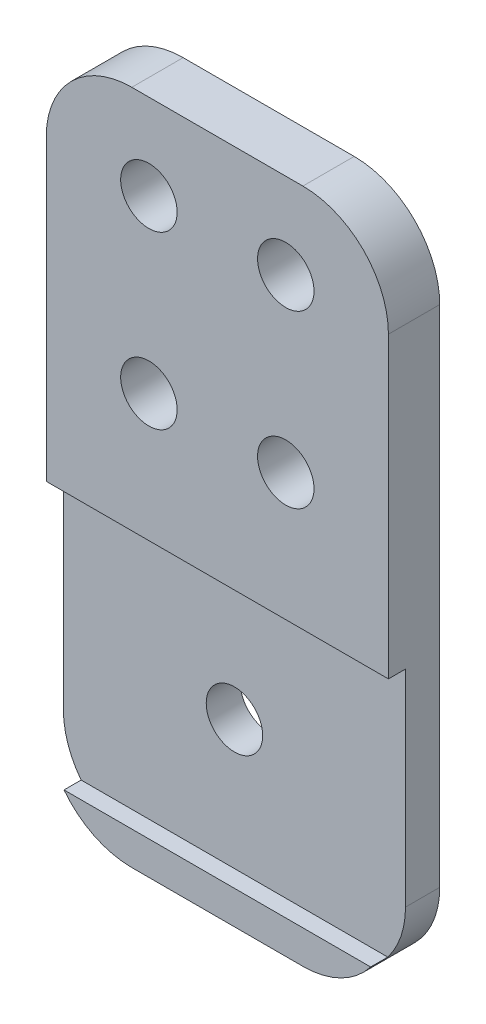
from build123d import *

# Parameters (mm, degrees)
SKETCH_2_W          = 20
SKETCH_2_H          = 39.5
SKETCH_2_R          = 1.65
EXTRUDE_1_DEPTH     = 3
SKETCH_3_W          = 20
SKETCH_3_H          = 15.1
CUT_EXTRUDE_1_DEPTH = 1
FILLET_2_R          = 5


with BuildPart() as part:
    # ｽｹｯﾁ2 → ﾎﾞｽ - 押し出し1 (new body)
    with BuildSketch(Plane.XY):
        with Locations((0, -9.75)):
            Rectangle(SKETCH_2_W, SKETCH_2_H)
        with Locations((-4, 5)):
            Circle(SKETCH_2_R, mode=Mode.SUBTRACT)
        with Locations((-4, -5)):
            Circle(SKETCH_2_R, mode=Mode.SUBTRACT)
        with Locations((4, -5)):
            Circle(SKETCH_2_R, mode=Mode.SUBTRACT)
        with Locations((4, 5)):
            Circle(SKETCH_2_R, mode=Mode.SUBTRACT)
        with Locations((0, -20)):
            Circle(SKETCH_2_R, mode=Mode.SUBTRACT)
    extrude(amount=EXTRUDE_1_DEPTH)

    # ｽｹｯﾁ3 → ｶｯﾄ - 押し出し1 (cut)
    with BuildSketch(Plane.XY.offset(3)):
        with Locations((0, -20)):
            Rectangle(SKETCH_3_W, SKETCH_3_H)
    extrude(amount=-CUT_EXTRUDE_1_DEPTH, mode=Mode.SUBTRACT)

    # ﾌｨﾚｯﾄ2
    fillet_2_edges = [part.edges().sort_by_distance(p)[0] for p in [
        (-10, -29.5, 1.5),
        (10, -29.5, 1.5),
        (-10, 10, 1.5),
        (10, 10, 1.5),
    ]]
    fillet(fillet_2_edges, radius=FILLET_2_R)


solid = part.part
